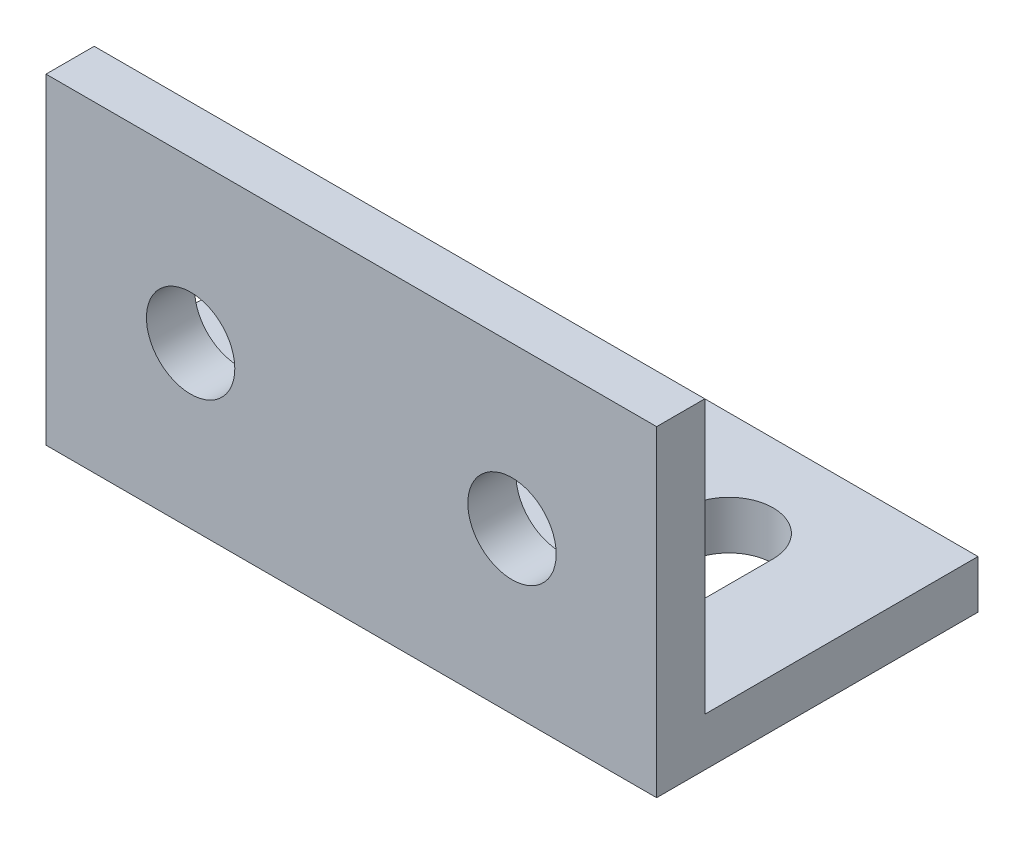
from build123d import *

# Parameters (mm, degrees)
EXTRUDE_1_DEPTH     = 38
SKETCH_2_R          = 2.75
CUT_EXTRUDE_1_DEPTH = 21
CUT_EXTRUDE_2_DEPTH = 21


with BuildPart() as part:
    # 草图1 → 凸台-拉伸1 (new body)
    with BuildSketch(Plane(origin=(0, 0, 0), x_dir=(0, 0, -1), z_dir=(1, 0, 0))):
        Polygon((0, 0), (20, 0), (20, 3), (3, 3), (3, 20), (0, 20), align=None)
    extrude(amount=EXTRUDE_1_DEPTH)

    # 草图2 → 切除-拉伸1 (cut, through all)
    with BuildSketch(Plane.XY):
        with Locations((9, 10)):
            Circle(SKETCH_2_R)
        with Locations((29, 10)):
            Circle(SKETCH_2_R)
    extrude(amount=-CUT_EXTRUDE_1_DEPTH, mode=Mode.SUBTRACT)

    # 草图3 → 切除-拉伸2 (cut, through all)
    with BuildSketch(Plane.XZ):
        with BuildLine():
            Line((6.25, -13.5), (6.25, -6.5))
            ThreePointArc((6.25, -6.5), (9, -3.75), (11.75, -6.5))
            Line((11.75, -6.5), (11.75, -13.5))
            ThreePointArc((11.75, -13.5), (9, -16.25), (6.25, -13.5))
        make_face()
        with BuildLine():
            Line((26.25, -13.5), (26.25, -6.5))
            ThreePointArc((26.25, -6.5), (29, -3.75), (31.75, -6.5))
            Line((31.75, -6.5), (31.75, -13.5))
            ThreePointArc((31.75, -13.5), (29, -16.25), (26.25, -13.5))
        make_face()
    extrude(amount=-CUT_EXTRUDE_2_DEPTH, mode=Mode.SUBTRACT)


solid = part.part
